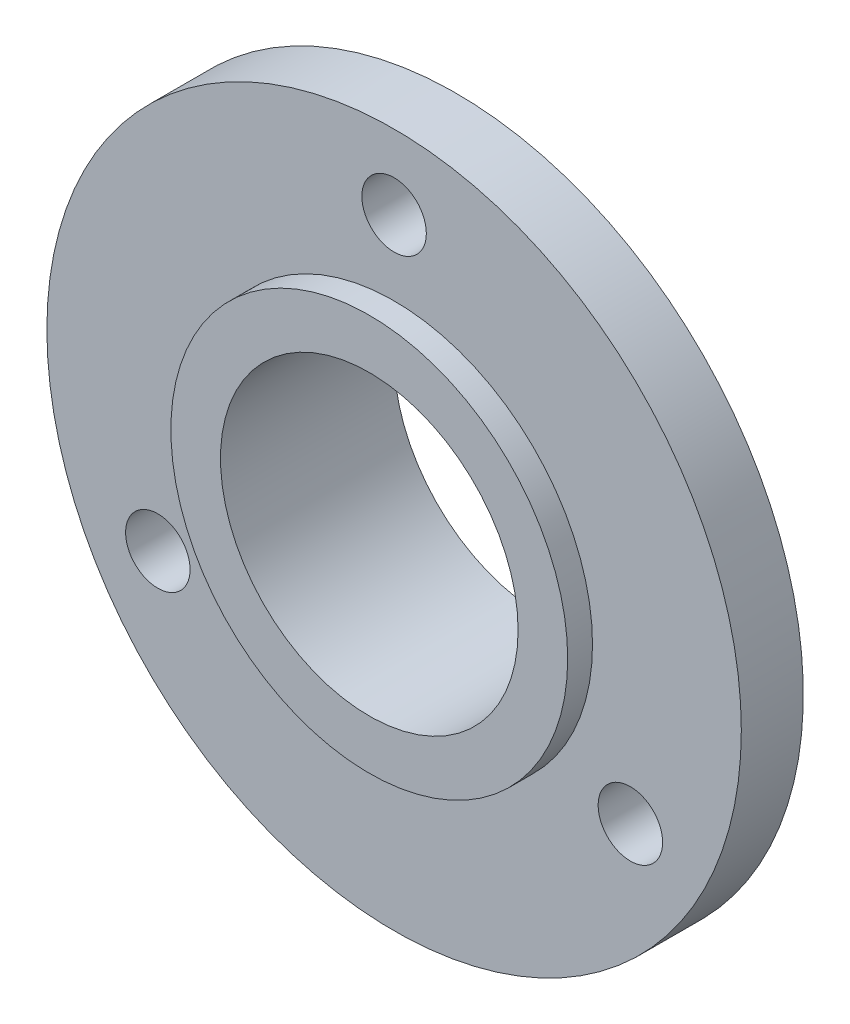
from build123d import *

# Parameters (mm, degrees)
ESQUISSE1_R                  = 14
ESQUISSE1_R_2                = 6
BOSS_EXTRU_1_DEPTH           = 7
ESQUISSE2_R                  = 14
ESQUISSE2_R_2                = 8
ENL_V_MAT_EXTRU_1_DEPTH      = 1
ESQUISSE3_OUTSIDE_W          = 38.042
ESQUISSE3_OUTSIDE_H          = 38.042
ESQUISSE3_OUTSIDE_R          = 8
ENL_V_MAT_EXTRU_2_DEPTH      = 3.5
ESQUISSE4_R                  = 1.3
ENL_V_MAT_EXTRU_3_DEPTH      = 8
R_P_TITION_CIRCULAIRE1_COUNT = 3


with BuildPart() as part:
    # Esquisse1 → Boss.-Extru.1 (new body)
    with BuildSketch(Plane.XY):
        Circle(ESQUISSE1_R)
        Circle(ESQUISSE1_R_2, mode=Mode.SUBTRACT)
    extrude(amount=BOSS_EXTRU_1_DEPTH)

    # Esquisse2 → Enlèv. mat.-Extru.1 (cut)
    with BuildSketch(Plane.XY.offset(7)):
        Circle(ESQUISSE2_R)
        Circle(ESQUISSE2_R_2, mode=Mode.SUBTRACT)
    extrude(amount=-ENL_V_MAT_EXTRU_1_DEPTH, mode=Mode.SUBTRACT)

    # Esquisse3 outside → Enlèv. mat.-Extru.2 (cut)
    with BuildSketch(Plane(origin=(0, 0, 0), x_dir=(-1, 0, 0), z_dir=(0, 0, -1))):
        Rectangle(ESQUISSE3_OUTSIDE_W, ESQUISSE3_OUTSIDE_H)
        Circle(ESQUISSE3_OUTSIDE_R, mode=Mode.SUBTRACT)
    extrude(amount=-ENL_V_MAT_EXTRU_2_DEPTH, mode=Mode.SUBTRACT)

    # Esquisse4 → Enlèv. mat.-Extru.3 (cut)
    with BuildSketch(Plane.XY):
        with Locations((0, 11)):
            Circle(ESQUISSE4_R)
    enl_v_mat_extru_3 = extrude(amount=ENL_V_MAT_EXTRU_3_DEPTH, mode=Mode.SUBTRACT)

    # Répétition circulaire1: Enlèv. mat.-Extru.3 ×3 about axis
    r_p_tition_circulaire1_axis = Axis((0, 0, 0), (0, 0, 1))
    for i in range(1, R_P_TITION_CIRCULAIRE1_COUNT):
        add(enl_v_mat_extru_3.rotate(r_p_tition_circulaire1_axis, i * 360 / R_P_TITION_CIRCULAIRE1_COUNT), mode=Mode.SUBTRACT)


solid = part.part
